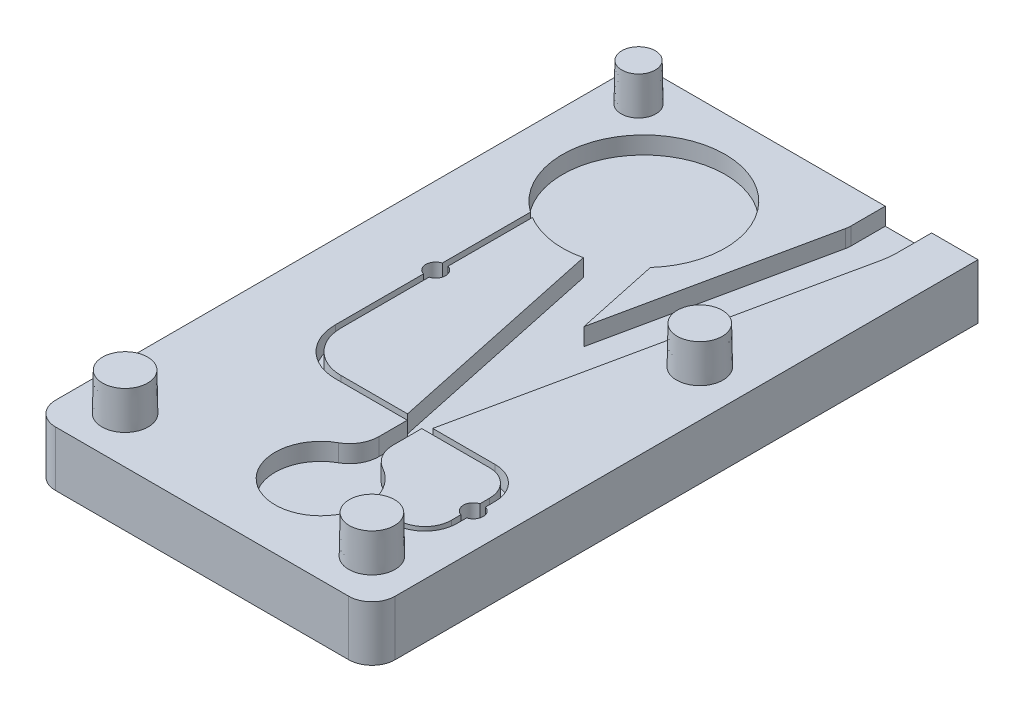
from build123d import *

# Parameters (mm, degrees)
SKETCH1_W                     = 46.5
SKETCH1_H                     = 83
BOSS_EXTRUDE1_DEPTH           = 7.540625
CUT_EXTRUDE3_START            = 7.540625
CUT_EXTRUDE3_DEPTH            = 2.38125
SKETCH10_R                    = 1.35255
CUT_EXTRUDE6_DEPTH            = 4.76885
SKETCH12_R                    = 3.175
BOSS_EXTRUDE2_DEPTH           = 5.159375
BOSS_EXTRUDE2_DRAFT           = 1
BOSS_EXTRUDE2_PROFILE_2_DEPTH = 5.159375
BOSS_EXTRUDE2_PROFILE_2_DRAFT = 1
BOSS_EXTRUDE2_PROFILE_3_DEPTH = 5.159375
BOSS_EXTRUDE2_PROFILE_3_DRAFT = 1
SKETCH12_R_2                  = 2.38125
BOSS_EXTRUDE2_PROFILE_4_DEPTH = 5.159375
BOSS_EXTRUDE2_PROFILE_4_DRAFT = 1
FILLET1_R                     = 3.175


with BuildPart() as part:
    # Sketch1 → Boss-Extrude1 (new body)
    with BuildSketch(Plane(origin=(0, 0, 0), x_dir=(1, 0, 0), z_dir=(0, 1, 0))):
        Rectangle(SKETCH1_W, SKETCH1_H)
    extrude(amount=BOSS_EXTRUDE1_DEPTH)

    # Sketch2 → Cut-Extrude3 (cut)
    with BuildSketch(Plane(origin=(0, 0, 0), x_dir=(1, 0, 0), z_dir=(0, 1, 0)).offset(CUT_EXTRUDE3_START)):
        with BuildLine():
            Line((5.926342072, -15.8450122), (16.691855897, 34.802748287))
            ThreePointArc((16.691855897, 34.802748287), (16.847821053, 35.78747353), (16.9, 36.783107142))
            Line((16.9, 36.783107142), (16.9, 41.5))
            Line((16.9, 41.5), (10.55, 41.5))
            Line((10.55, 41.5), (10.55, 36.783107142))
            ThreePointArc((10.55, 36.783107142), (10.532607018, 36.451229271), (10.480618632, 36.122987524))
            Line((10.480618632, 36.122987524), (4.2, 6.575))
            Line((4.2, 6.575), (1.742353127, 18.137319476))
            ThreePointArc((1.742353127, 18.137319476), (-7.787687338, 36.612083158), (-13.035, 16.49730565))
            Line((-13.035, 16.49730565), (-13.035, -10.23))
            ThreePointArc((-13.035, -10.23), (-11.164876798, -14.744876798), (-6.65, -16.615))
            Line((-6.65, -16.615), (3.2078125, -16.615))
            Line((3.2078125, -16.615), (3.2078125, -20.512873774))
            ThreePointArc((3.2078125, -20.512873774), (2.656919843, -22.538622657), (1.155983232, -24.006386448))
            ThreePointArc((1.155983232, -24.006386448), (0.870208506, -34.75413874), (10.438131483, -29.8499878))
            Line((10.438131483, -29.8499878), (14.4748, -29.8499878))
            ThreePointArc((14.4748, -29.8499878), (17.575454609, -28.565654609), (18.8597878, -25.465))
            Line((18.8597878, -25.465), (18.8597878, -20.23))
            ThreePointArc((18.8597878, -20.23), (17.575454609, -17.129345391), (14.4748, -15.8450122))
            Line((14.4748, -15.8450122), (5.926342072, -15.8450122))
        make_face()
        with BuildLine():
            Line((14.4748, -29.08), (10.43813073, -29.08))
            ThreePointArc((10.43813073, -29.08), (9.489135484, -26.135203334), (7.244016768, -24.006386448))
            ThreePointArc((7.244016768, -24.006386448), (5.743080157, -22.538622657), (5.1921875, -20.512873774))
            Line((5.1921875, -20.512873774), (5.1921875, -16.615))
            Line((5.1921875, -16.615), (14.4748, -16.615))
            ThreePointArc((14.4748, -16.615), (17.030991014, -17.673808986), (18.0898, -20.23))
            Line((18.0898, -20.23), (18.0898, -25.465))
            ThreePointArc((18.0898, -25.465), (17.030991014, -28.021191014), (14.4748, -29.08))
        make_face(mode=Mode.SUBTRACT)
        with BuildLine():
            Line((-4.021712531, 14.713303237), (2.473657928, -15.8450122))
            Line((2.473657928, -15.8450122), (-6.65, -15.8450122))
            ThreePointArc((-6.65, -15.8450122), (-10.620413203, -14.200413203), (-12.2650122, -10.23))
            Line((-12.2650122, -10.23), (-12.2650122, 15.993340762))
            ThreePointArc((-12.2650122, 15.993340762), (-8.267823292, 14.551807439), (-4.021712531, 14.713303237))
        make_face(mode=Mode.SUBTRACT)
    extrude(amount=-CUT_EXTRUDE3_DEPTH, mode=Mode.SUBTRACT)

    # Sketch10 → Cut-Extrude6 (cut)
    with BuildSketch(Plane(origin=(0, 7.540625, 0), x_dir=(1, 0, 0), z_dir=(0, 1, 0))):
        with Locations(Location((18.4747939, -22.8475, 0), (0, 0, 270))):
            Circle(SKETCH10_R)
        with Locations(Location((-12.6500061, 3.133652825, 0), (0, 0, 270))):
            Circle(SKETCH10_R)
    extrude(amount=-CUT_EXTRUDE6_DEPTH, mode=Mode.SUBTRACT)


with BuildPart() as boss_extrude2_tool:
    # Sketch12 → Boss-Extrude2 (with draft: the straight prism first)
    with BuildSketch(Plane(origin=(0, 7.540625, 0), x_dir=(1, 0, 0), z_dir=(0, 1, 0))):
        with Locations((-16.9, -35.15)):
            Circle(SKETCH12_R)
    extrude(amount=BOSS_EXTRUDE2_DEPTH)
    # Boss-Extrude2: the draft: its side faces are tilted about the plane it starts from
    boss_extrude2_sides = [boss_extrude2_tool.faces().sort_by_distance(p)[0] for p in [
        (-20.075, 10.1203125, 35.15),
    ]]
    draft(boss_extrude2_sides, Plane(origin=(0, 7.540625, 0), x_dir=(1, 0, 0), z_dir=(0, 1, 0)), BOSS_EXTRUDE2_DRAFT)


with BuildPart() as part_1:
    add(part.part)

    # Boss-Extrude2: add boss_extrude2_tool
    add(boss_extrude2_tool.part)


with BuildPart() as boss_extrude2_profile_2_tool:
    # Sketch12 → Boss-Extrude2 profile 2 (with draft: the straight prism first)
    with BuildSketch(Plane(origin=(0, 7.540625, 0), x_dir=(1, 0, 0), z_dir=(0, 1, 0))):
        with Locations((16.9, -35.15)):
            Circle(SKETCH12_R)
    extrude(amount=BOSS_EXTRUDE2_PROFILE_2_DEPTH)
    # Boss-Extrude2 profile 2: the draft: its side faces are tilted about the plane it starts from
    boss_extrude2_profile_2_sides = [boss_extrude2_profile_2_tool.faces().sort_by_distance(p)[0] for p in [
        (13.725, 10.1203125, 35.15),
    ]]
    draft(boss_extrude2_profile_2_sides, Plane(origin=(0, 7.540625, 0), x_dir=(1, 0, 0), z_dir=(0, 1, 0)), BOSS_EXTRUDE2_PROFILE_2_DRAFT)


with BuildPart() as part_2:
    add(part_1.part)

    # Boss-Extrude2 profile 2: add boss_extrude2_profile_2_tool
    add(boss_extrude2_profile_2_tool.part)


with BuildPart() as boss_extrude2_profile_3_tool:
    # Sketch12 → Boss-Extrude2 profile 3 (with draft: the straight prism first)
    with BuildSketch(Plane(origin=(0, 7.540625, 0), x_dir=(1, 0, 0), z_dir=(0, 1, 0))):
        with Locations((16.9, 9.75)):
            Circle(SKETCH12_R)
    extrude(amount=BOSS_EXTRUDE2_PROFILE_3_DEPTH)
    # Boss-Extrude2 profile 3: the draft: its side faces are tilted about the plane it starts from
    boss_extrude2_profile_3_sides = [boss_extrude2_profile_3_tool.faces().sort_by_distance(p)[0] for p in [
        (13.725, 10.1203125, -9.75),
    ]]
    draft(boss_extrude2_profile_3_sides, Plane(origin=(0, 7.540625, 0), x_dir=(1, 0, 0), z_dir=(0, 1, 0)), BOSS_EXTRUDE2_PROFILE_3_DRAFT)


with BuildPart() as part_3:
    add(part_2.part)

    # Boss-Extrude2 profile 3: add boss_extrude2_profile_3_tool
    add(boss_extrude2_profile_3_tool.part)


with BuildPart() as boss_extrude2_profile_4_tool:
    # Sketch12 → Boss-Extrude2 profile 4 (with draft: the straight prism first)
    with BuildSketch(Plane(origin=(0, 7.540625, 0), x_dir=(1, 0, 0), z_dir=(0, 1, 0))):
        with Locations((-18.4748, 36.7375)):
            Circle(SKETCH12_R_2)
    extrude(amount=BOSS_EXTRUDE2_PROFILE_4_DEPTH)
    # Boss-Extrude2 profile 4: the draft: its side faces are tilted about the plane it starts from
    boss_extrude2_profile_4_sides = [boss_extrude2_profile_4_tool.faces().sort_by_distance(p)[0] for p in [
        (-20.85605, 10.1203125, -36.7375),
    ]]
    draft(boss_extrude2_profile_4_sides, Plane(origin=(0, 7.540625, 0), x_dir=(1, 0, 0), z_dir=(0, 1, 0)), BOSS_EXTRUDE2_PROFILE_4_DRAFT)


with BuildPart() as part_4:
    add(part_3.part)

    # Boss-Extrude2 profile 4: add boss_extrude2_profile_4_tool
    add(boss_extrude2_profile_4_tool.part)

    # Fillet1
    fillet1_edges = [part_4.edges().sort_by_distance(p)[0] for p in [
        (23.25, 3.7703125, 41.5),
        (-23.25, 3.7703125, 41.5),
        (-23.25, 3.7703125, -41.5),
    ]]
    fillet(fillet1_edges, radius=FILLET1_R)


solid = part_4.part
